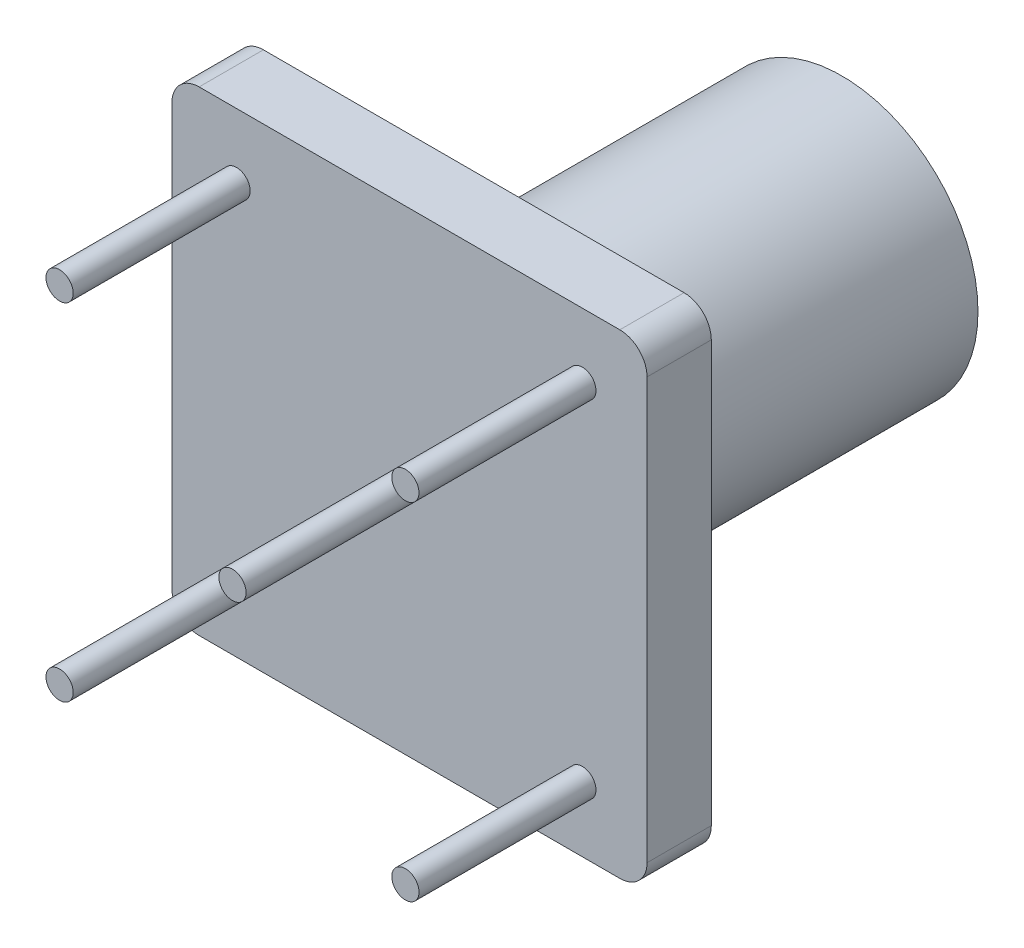
from build123d import *

# Parameters (mm, degrees)
EXTRUDE1_DEPTH     = 2.36
SKETCH2_R          = 5
EXTRUDE2_DEPTH     = 13.52
SKETCH3_R          = 4.5
CUT_EXTRUDE1_DEPTH = 13.52
SKETCH4_R          = 0.5
EXTRUDE3_DEPTH     = 6.5
SKETCH5_R          = 0.5
EXTRUDE4_DEPTH     = 9


with BuildPart() as part:
    # Sketch1 → Extrude1 (new body)
    with BuildSketch(Plane.XY):
        with BuildLine():
            Line((1, 0), (16.45, 0))
            ThreePointArc((16.45, 0), (17.157106781, -0.292893219), (17.45, -1))
            Line((17.45, -1), (17.45, -16.45))
            ThreePointArc((17.45, -16.45), (17.157106781, -17.157106781), (16.45, -17.45))
            Line((16.45, -17.45), (1, -17.45))
            ThreePointArc((1, -17.45), (0.292893219, -17.157106781), (0, -16.45))
            Line((0, -16.45), (0, -1))
            ThreePointArc((0, -1), (0.292893219, -0.292893219), (1, 0))
        make_face()
    extrude(amount=EXTRUDE1_DEPTH)

    # Sketch2 → Extrude2 (add)
    with BuildSketch(Plane(origin=(0, 0, 0), x_dir=(-1, 0, 0), z_dir=(0, 0, -1))):
        with Locations((-8.725, -8.725)):
            Circle(SKETCH2_R)
    extrude(amount=EXTRUDE2_DEPTH)

    # Sketch3 → Cut-Extrude1 (cut)
    with BuildSketch(Plane(origin=(0, 0, -13.52), x_dir=(-1, 0, 0), z_dir=(0, 0, -1))):
        with Locations((-8.725, -8.725)):
            Circle(SKETCH3_R)
    extrude(amount=-CUT_EXTRUDE1_DEPTH, mode=Mode.SUBTRACT)

    # Sketch4 → Extrude3 (add)
    with BuildSketch(Plane.XY.offset(2.36)):
        with Locations((8.725, -8.725)):
            Circle(SKETCH4_R)
        with Locations((15.075, -2.375)):
            Circle(SKETCH4_R)
        with Locations((2.375, -2.375)):
            Circle(SKETCH4_R)
        with Locations((2.375, -15.075)):
            Circle(SKETCH4_R)
        with Locations((15.075, -15.075)):
            Circle(SKETCH4_R)
    extrude(amount=EXTRUDE3_DEPTH)

    # Sketch5 → Extrude4 (add)
    with BuildSketch(Plane(origin=(0, 0, 0), x_dir=(-1, 0, 0), z_dir=(0, 0, -1))):
        with Locations((-8.725, -8.725)):
            Circle(SKETCH5_R)
    extrude(amount=EXTRUDE4_DEPTH)


solid = part.part
